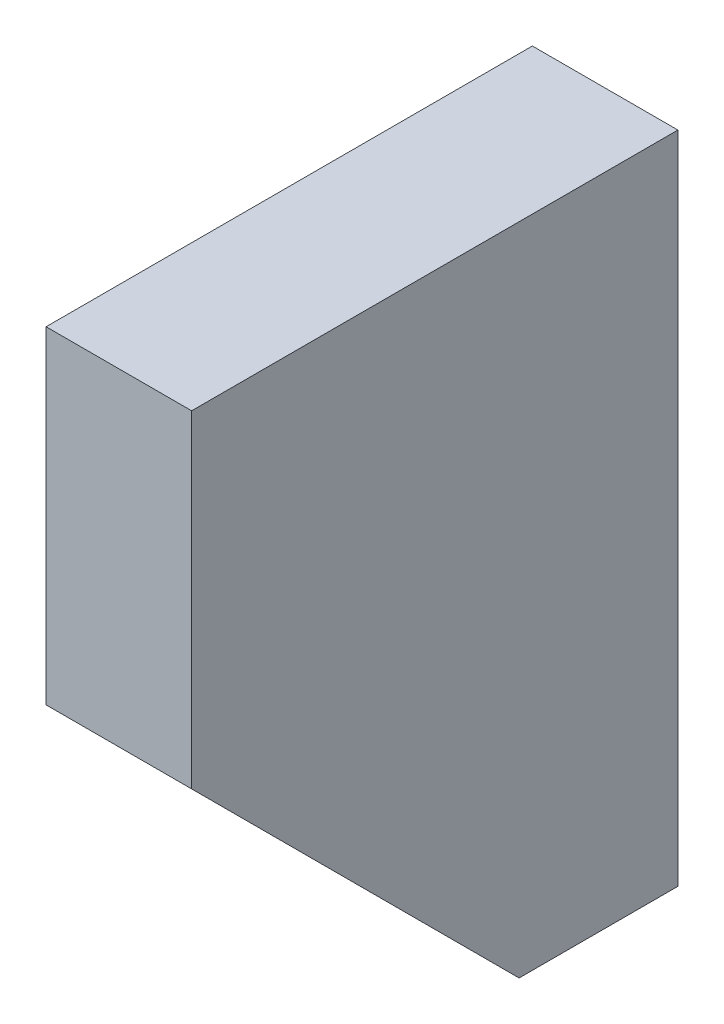
from build123d import *

# Parameters (mm, degrees)
ESQUISSE1_W             = 22
ESQUISSE1_H             = 99
BOSS_EXTRU_1_DEPTH      = 73.5
ENL_V_MAT_EXTRU_1_DEPTH = 35


with BuildPart() as part:
    # Esquisse1 → Boss.-Extru.1 (new body)
    with BuildSketch(Plane.XY):
        with Locations((11, 49.5)):
            Rectangle(ESQUISSE1_W, ESQUISSE1_H)
    extrude(amount=BOSS_EXTRU_1_DEPTH)

    # Esquisse2 → Enlèv. mat.-Extru.1 (cut)
    with BuildSketch(Plane.ZY):
        Polygon((24, 0), (73.5, 49.5), (73.5, 0), align=None)
    extrude(amount=-ENL_V_MAT_EXTRU_1_DEPTH, mode=Mode.SUBTRACT)


solid = part.part
